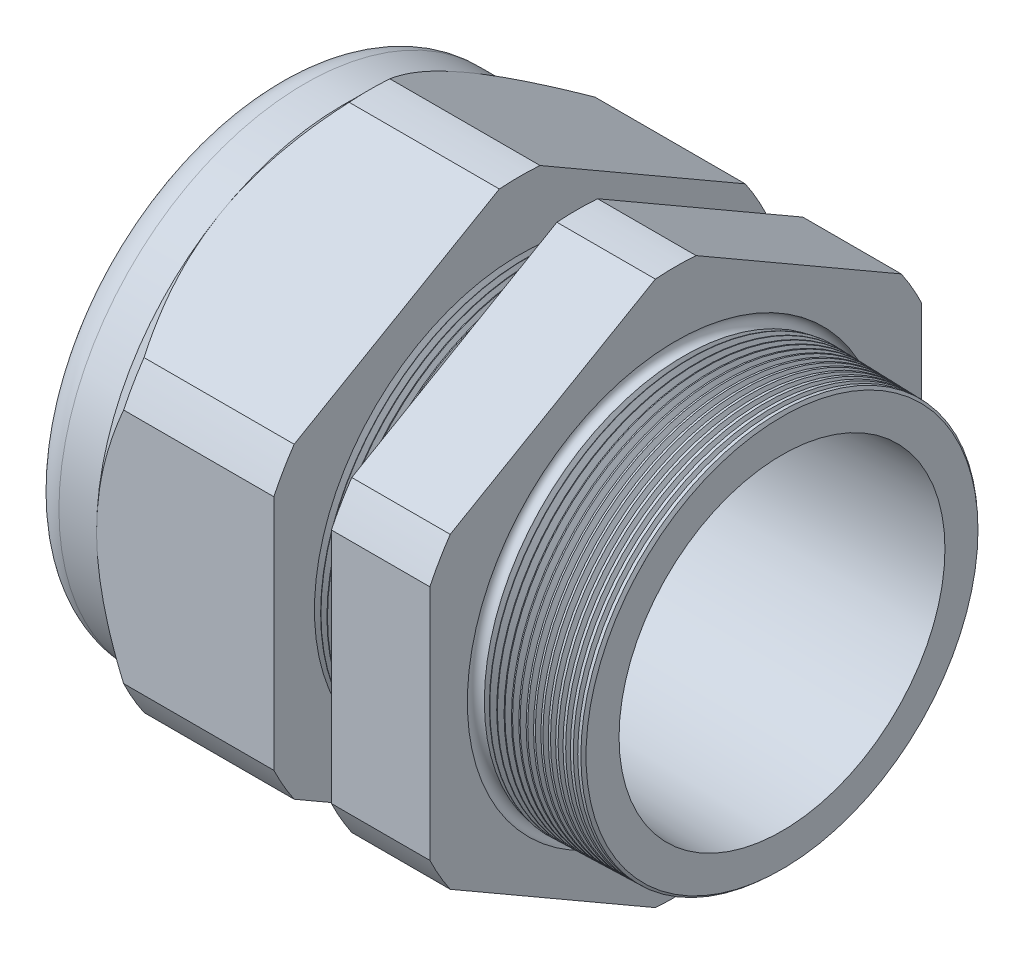
from build123d import *

# Parameters (mm, degrees)
SKETCH12_OUTSIDE_W = 157.992
SKETCH12_OUTSIDE_H = 157.992
CUT_EXTRUDE2_DEPTH = 54.5760168
FILLET4_R          = 3.81
SKETCH19_OUTSIDE_W = 91.722
SKETCH19_OUTSIDE_H = 98.316
SKETCH19_OUTSIDE_R = 29.972
CUT_EXTRUDE3_DEPTH = 3.99796
CUT_EXTRUDE3_DRAFT = -45
CHAMFER1_SIZE      = 0.260919487
CHAMFER1_SIZE2     = 0.254
SKETCH21_R         = 19.05
PLUG_DEPTH         = 11.43
SKETCH22_R         = 18.796
CUT_EXTRUDE4_DEPTH = 0.508
SKETCH27_R         = 6.985
PLUGHOLES_DEPTH    = 62.468
CIRPATTERN1_COUNT  = 3
LPATTERN1_COUNT    = 9
LPATTERN1_PITCH    = 0.762
LPATTERN2_COUNT    = 15
LPATTERN2_PITCH    = 0.889
SKETCH32_R         = 0.889


with BuildPart() as part:
    # Sketch10 → Revolve2 (revolve)
    with BuildSketch(Plane.XY, mode=Mode.PRIVATE) as revolve2_sk:
        Polygon((-56.896, 19.05), (-26.89359112, 19.05), (5.08, 19.863742051), (5.08, 24.181742051), (-7.874, 24.520954479), (-7.874, 59.944), (-19.873976, 59.944), (-19.873976, 24.835184909), (-26.89359112, 25.019), (-26.89359112, 59.944), (-48.4960168, 59.944), (-48.4960168, 29.972), (-56.896, 29.972), align=None)
    revolve(revolve2_sk.sketch.rotate(Axis((0, 0, 0), (-1, 0, 0)), 90), axis=Axis((0, 0, 0), (-1, 0, 0)))  # turned: the seam where the file's is

    # Sketch12 outside → Cut-Extrude2 (cut, through all)
    with BuildSketch(Plane.ZY.offset(48.4960168)):
        Rectangle(SKETCH12_OUTSIDE_W, SKETCH12_OUTSIDE_H)
        with BuildLine():
            Line((-2.480993384, 33.176282338), (-27.491006616, 18.736744466))
            ThreePointArc((-27.491006616, 18.736744466), (-28.811729876, 16.63446), (-29.972, 14.439537872))
            Line((-29.972, 14.439537872), (-29.972, -14.439537872))
            ThreePointArc((-29.972, -14.439537872), (-28.811729876, -16.63446), (-27.491006616, -18.736744466))
            Line((-27.491006616, -18.736744466), (-2.480993384, -33.176282338))
            ThreePointArc((-2.480993384, -33.176282338), (0, -33.26892), (2.480993384, -33.176282338))
            Line((2.480993384, -33.176282338), (27.491006616, -18.736744466))
            ThreePointArc((27.491006616, -18.736744466), (28.811729876, -16.63446), (29.972, -14.439537872))
            Line((29.972, -14.439537872), (29.972, 14.439537872))
            ThreePointArc((29.972, 14.439537872), (28.811729876, 16.63446), (27.491006616, 18.736744466))
            Line((27.491006616, 18.736744466), (2.480993384, 33.176282338))
            ThreePointArc((2.480993384, 33.176282338), (0, 33.26892), (-2.480993384, 33.176282338))
        make_face(mode=Mode.SUBTRACT)
    extrude(amount=-CUT_EXTRUDE2_DEPTH, mode=Mode.SUBTRACT)

    # Fillet4
    fillet4_edges = [part.edges().sort_by_distance(p)[0] for p in [
        (-56.896, 0, 29.972),
    ]]
    fillet(fillet4_edges, radius=FILLET4_R)


with BuildPart() as cut_extrude3_tool:
    # Sketch19 outside → Cut-Extrude3 (with draft: the straight prism first)
    with BuildSketch(Plane.ZY.offset(48.4960168)):
        Rectangle(SKETCH19_OUTSIDE_W, SKETCH19_OUTSIDE_H)
        Circle(SKETCH19_OUTSIDE_R, mode=Mode.SUBTRACT)
    extrude(amount=-CUT_EXTRUDE3_DEPTH)
    # Cut-Extrude3: the draft: its side faces are tilted about the plane it starts from
    cut_extrude3_sides = [cut_extrude3_tool.faces().sort_by_distance(p)[0] for p in [
        (-46.4970368, -49.158, 0),
        (-46.4970368, 0, 45.861),
        (-46.4970368, 49.158, 0),
        (-46.4970368, 0, -45.861),
        (-46.4970368, 0, -29.972),
    ]]
    draft(cut_extrude3_sides, Plane.ZY.offset(48.4960168), CUT_EXTRUDE3_DRAFT)


with BuildPart() as part_1:
    add(part.part)

    # Cut-Extrude3: cut by cut_extrude3_tool
    add(cut_extrude3_tool.part, mode=Mode.SUBTRACT)

    # Chamfer1
    chamfer1_edges = [part_1.edges().sort_by_distance(p)[0] for p in [
        (5.08, 0, 24.181742051),
    ]]
    chamfer1_side = [part_1.faces().sort_by_distance(p)[0] for p in [
        (5.08, 0, 20.547705002),
    ]]
    chamfer(chamfer1_edges, length=CHAMFER1_SIZE, length2=CHAMFER1_SIZE2, reference=chamfer1_side[0])

    # Sketch29 → Cut-Revolve1 (revolve, cut)
    with BuildSketch(Plane.XY, mode=Mode.PRIVATE) as cut_revolve1_sk:
        Polygon((-26.89359112, 25.019), (-26.160607539, 24.999806149), (-26.543721692, 24.374620673), align=None)
    cut_revolve1 = revolve(cut_revolve1_sk.sketch.rotate(Axis((0, 0, 0), (-1, 0, 0)), 90), axis=Axis((0, 0, 0), (-1, 0, 0)), mode=Mode.SUBTRACT)  # turned: the seam where the file's is

    # LPattern1: Cut-Revolve1 ×9
    with Locations(*[(i * LPATTERN1_PITCH, 0, 0) for i in range(1, LPATTERN1_COUNT)]):
        add(cut_revolve1, mode=Mode.SUBTRACT)

    # Sketch30 → Cut-Revolve2 (revolve, cut)
    with BuildSketch(Plane.XY, mode=Mode.PRIVATE) as cut_revolve2_sk:
        Polygon((-7.874, 24.520954479), (-6.994419703, 24.497921858), (-7.454156686, 23.747699287), align=None)
    cut_revolve2 = revolve(cut_revolve2_sk.sketch.rotate(Axis((0, 0, 0), (-1, 0, 0)), 270), axis=Axis((0, 0, 0), (-1, 0, 0)), mode=Mode.SUBTRACT)  # turned: the seam where the file's is

    # LPattern2: Cut-Revolve2 ×15
    with Locations(*[(i * LPATTERN2_PITCH, 0, 0) for i in range(1, LPATTERN2_COUNT)]):
        add(cut_revolve2, mode=Mode.SUBTRACT)

    # Sketch32 → Cut-Revolve3 (revolve, cut)
    with BuildSketch(Plane.XY, mode=Mode.PRIVATE) as cut_revolve3_sk:
        with Locations((-7.747, 24.520954479)):
            Circle(SKETCH32_R)
    revolve(cut_revolve3_sk.sketch.rotate(Axis((0, 0, 0), (-1, 0, 0)), 270), axis=Axis((0, 0, 0), (-1, 0, 0)), mode=Mode.SUBTRACT)  # turned: the seam where the file's is


with BuildPart() as body_2:
    # Sketch21 → plug (new body)
    with BuildSketch(Plane.ZY.offset(56.896)):
        Circle(SKETCH21_R)
    extrude(amount=-PLUG_DEPTH)

    # Sketch22 → Cut-Extrude4 (cut)
    with BuildSketch(Plane.ZY.offset(56.896)):
        Circle(SKETCH22_R)
    extrude(amount=-CUT_EXTRUDE4_DEPTH, mode=Mode.SUBTRACT)

    # Sketch27 → plugholes (cut, through all)
    with BuildSketch(Plane.ZY.offset(56.388)):
        with Locations((-11.78306, 0)):
            Circle(SKETCH27_R)
    plugholes = extrude(amount=-PLUGHOLES_DEPTH, mode=Mode.SUBTRACT)

    # CirPattern1: plugholes ×3 about axis
    cirpattern1_axis = Axis((0, 0, 0), (1, 0, 0))
    for i in range(1, CIRPATTERN1_COUNT):
        add(plugholes.rotate(cirpattern1_axis, i * 360 / CIRPATTERN1_COUNT), mode=Mode.SUBTRACT)


solid = Compound([part_1.part, body_2.part])
